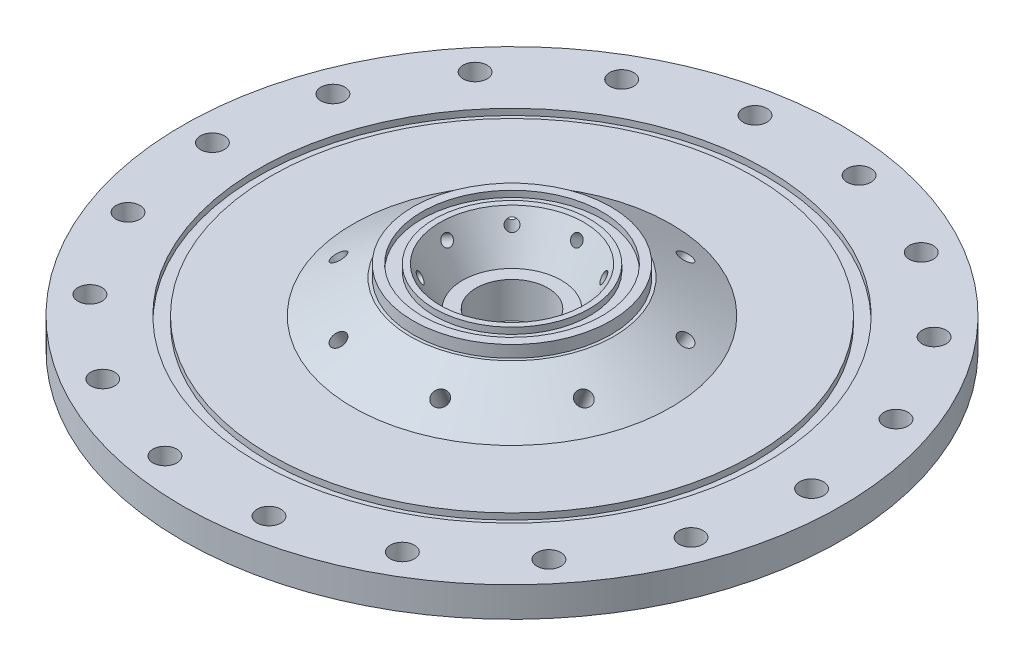
from build123d import *

# Parameters (mm, degrees)
SKETCH1_R           = 69.85
BOSS_EXTRUDE1_DEPTH = 6.35
SKETCH2_R           = 40.64
BOSS_EXTRUDE2_DEPTH = 9.525
SKETCH3_R           = 0.79375
CUT_EXTRUDE2_DEPTH  = 101.050290479
SKETCH4_R           = 36.83
SKETCH4_R_2         = 31.75
CUT_EXTRUDE3_DEPTH  = 3.175
SKETCH7_R           = 1.190625
CUT_EXTRUDE4_DEPTH  = 123.022150358
SKETCH10_R          = 1.5875
CUT_EXTRUDE5_DEPTH  = 105.494334611
CIRPATTERN1_COUNT   = 8
CUT_EXTRUDE6_START  = -2.54
SKETCH12_R          = 40.64
SKETCH12_R_2        = 20.955
CUT_EXTRUDE6_DEPTH  = 2.54
SKETCH15_R          = 2.54
CUT_EXTRUDE7_DEPTH  = 100.240972521
CIRPATTERN2_COUNT   = 18
SKETCH17_R          = 53.8353
SKETCH17_R_2        = 51.1937
CUT_EXTRUDE9_DEPTH  = 1.3208
SKETCH16_R          = 19.1008
SKETCH16_R_2        = 16.4592
CUT_EXTRUDE8_DEPTH  = 1.3208
SKETCH18_R          = 26.67
SKETCH18_R_2        = 12.7
CUT_EXTRUDE10_DEPTH = 2.54
SKETCH19_R          = 7.62
CUT_EXTRUDE11_DEPTH = 100.127140717


with BuildPart() as part:
    # Sketch1 → Boss-Extrude1 (new body)
    with BuildSketch(Plane(origin=(0, 0, 0), x_dir=(1, 0, 0), z_dir=(0, 1, 0))):
        Circle(SKETCH1_R)
    extrude(amount=BOSS_EXTRUDE1_DEPTH)

    # Sketch2 → Boss-Extrude2 (add)
    with BuildSketch(Plane(origin=(0, 6.35, 0), x_dir=(1, 0, 0), z_dir=(0, 1, 0))):
        Circle(SKETCH2_R)
    extrude(amount=BOSS_EXTRUDE2_DEPTH)

    # Sketch3 → Cut-Extrude2 (cut, symmetric)
    with BuildSketch(Plane(origin=(0, 15.875, 0), x_dir=(1, 0, 0), z_dir=(0, 1, 0))):
        with Locations((0, 5.08)):
            Circle(SKETCH3_R)
    cut_extrude2 = extrude(amount=CUT_EXTRUDE2_DEPTH, both=True, mode=Mode.SUBTRACT)

    # Sketch4 → Cut-Extrude3 (cut)
    with BuildSketch(Plane(origin=(0, 0, 0), x_dir=(1, 0, 0), z_dir=(0, 1, 0))):
        Circle(SKETCH4_R)
        Circle(SKETCH4_R_2, mode=Mode.SUBTRACT)
    extrude(amount=CUT_EXTRUDE3_DEPTH, mode=Mode.SUBTRACT)

    # Sketch7 → Cut-Extrude4 (cut, through all)
    with BuildSketch(Plane(origin=(-25.422795474, -14.677857811, 0), x_dir=(0.49999999999999506, -0.8660254037844415, 0), z_dir=(-0.8660254037844415, -0.49999999999999506, 0))):
        with Locations((-18.415, 0)):
            Circle(SKETCH7_R)
    cut_extrude4 = extrude(amount=-CUT_EXTRUDE4_DEPTH, mode=Mode.SUBTRACT)

    # Sketch10 → Cut-Extrude5 (cut, symmetric)
    with BuildSketch(Plane(origin=(-5.228252189, 9.801709106, 2.165612964), x_dir=(-0.8001031451912662, -0.49999999999999817, 0.33141357403559313), z_dir=(-0.4619397662556415, 0.8660254037844397, 0.19134171618254456))):
        with Locations((19.603418212, 0)):
            Circle(SKETCH10_R)
    cut_extrude5 = extrude(amount=CUT_EXTRUDE5_DEPTH, both=True, mode=Mode.SUBTRACT)

    # CirPattern1: Cut-Extrude2, Cut-Extrude4, Cut-Extrude5 ×8 about axis
    cirpattern1_axis = Axis((0, 15.875, 0), (0, -1, 0))
    add([cut_extrude2.rotate(cirpattern1_axis, i * 360 / CIRPATTERN1_COUNT) for i in range(1, CIRPATTERN1_COUNT)], mode=Mode.SUBTRACT)
    add([cut_extrude4.rotate(cirpattern1_axis, i * 360 / CIRPATTERN1_COUNT) for i in range(1, CIRPATTERN1_COUNT)], mode=Mode.SUBTRACT)
    add([cut_extrude5.rotate(cirpattern1_axis, i * 360 / CIRPATTERN1_COUNT) for i in range(1, CIRPATTERN1_COUNT)], mode=Mode.SUBTRACT)

    # Sketch11 → Cut-Revolve1 (revolve, cut)
    with BuildSketch(Plane.XY):
        Polygon((0, 15.875), (-15.24, 15.875), (-10.473973528, 7.62), (0, 7.62), align=None)
    revolve(axis=Axis((0, 0, 0), (0, 1, 0)), mode=Mode.SUBTRACT)

    # Sketch12 → Cut-Extrude6 (cut)
    with BuildSketch(Plane(origin=(0, 15.875, 0), x_dir=(1, 0, 0), z_dir=(0, 1, 0)).offset(CUT_EXTRUDE6_START)):
        Circle(SKETCH12_R)
        Circle(SKETCH12_R_2, mode=Mode.SUBTRACT)
    extrude(amount=CUT_EXTRUDE6_DEPTH, mode=Mode.SUBTRACT)

    # Sketch14 → Cut-Revolve2 (revolve, cut)
    with BuildSketch(Plane(origin=(0, 0, 0), x_dir=(0, 1, 0), z_dir=(0.38268343236509056, 0, 0.9238795325112864))):
        Polygon((6.35, 33.688374891), (13.335, 21.59), (13.335, 33.688374891), (14.011063176, 33.688374891), (14.011063176, 42.238101229), (6.35, 42.238101229), align=None)
    revolve(axis=Axis((0, 0, 0), (0, 1, 0)), mode=Mode.SUBTRACT)

    # Sketch15 → Cut-Extrude7 (cut, through all)
    with BuildSketch(Plane(origin=(0, 6.35, 0), x_dir=(1, 0, 0), z_dir=(0, 1, 0))):
        with Locations((63.5, 0)):
            Circle(SKETCH15_R)
    cut_extrude7 = extrude(amount=-CUT_EXTRUDE7_DEPTH, mode=Mode.SUBTRACT)

    # CirPattern2: Cut-Extrude7 ×18 about axis
    cirpattern2_axis = Axis((0, 6.35, 0), (0, -1, 0))
    for i in range(1, CIRPATTERN2_COUNT):
        add(cut_extrude7.rotate(cirpattern2_axis, i * 360 / CIRPATTERN2_COUNT), mode=Mode.SUBTRACT)

    # Sketch17 → Cut-Extrude9 (cut)
    with BuildSketch(Plane(origin=(0, 6.35, 0), x_dir=(1, 0, 0), z_dir=(0, 1, 0))):
        Circle(SKETCH17_R)
        Circle(SKETCH17_R_2, mode=Mode.SUBTRACT)
    extrude(amount=-CUT_EXTRUDE9_DEPTH, mode=Mode.SUBTRACT)

    # Sketch16 → Cut-Extrude8 (cut)
    with BuildSketch(Plane(origin=(0, 15.875, 0), x_dir=(1, 0, 0), z_dir=(0, 1, 0))):
        Circle(SKETCH16_R)
        Circle(SKETCH16_R_2, mode=Mode.SUBTRACT)
    extrude(amount=-CUT_EXTRUDE8_DEPTH, mode=Mode.SUBTRACT)

    # Sketch18 → Cut-Extrude10 (cut)
    with BuildSketch(Plane.XZ):
        Circle(SKETCH18_R)
        Circle(SKETCH18_R_2, mode=Mode.SUBTRACT)
    extrude(amount=-CUT_EXTRUDE10_DEPTH, mode=Mode.SUBTRACT)

    # Sketch19 → Cut-Extrude11 (cut, through all)
    with BuildSketch(Plane(origin=(0, 7.62, 0), x_dir=(1, 0, 0), z_dir=(0, 1, 0))):
        Circle(SKETCH19_R)
    extrude(amount=-CUT_EXTRUDE11_DEPTH, mode=Mode.SUBTRACT)


solid = part.part
